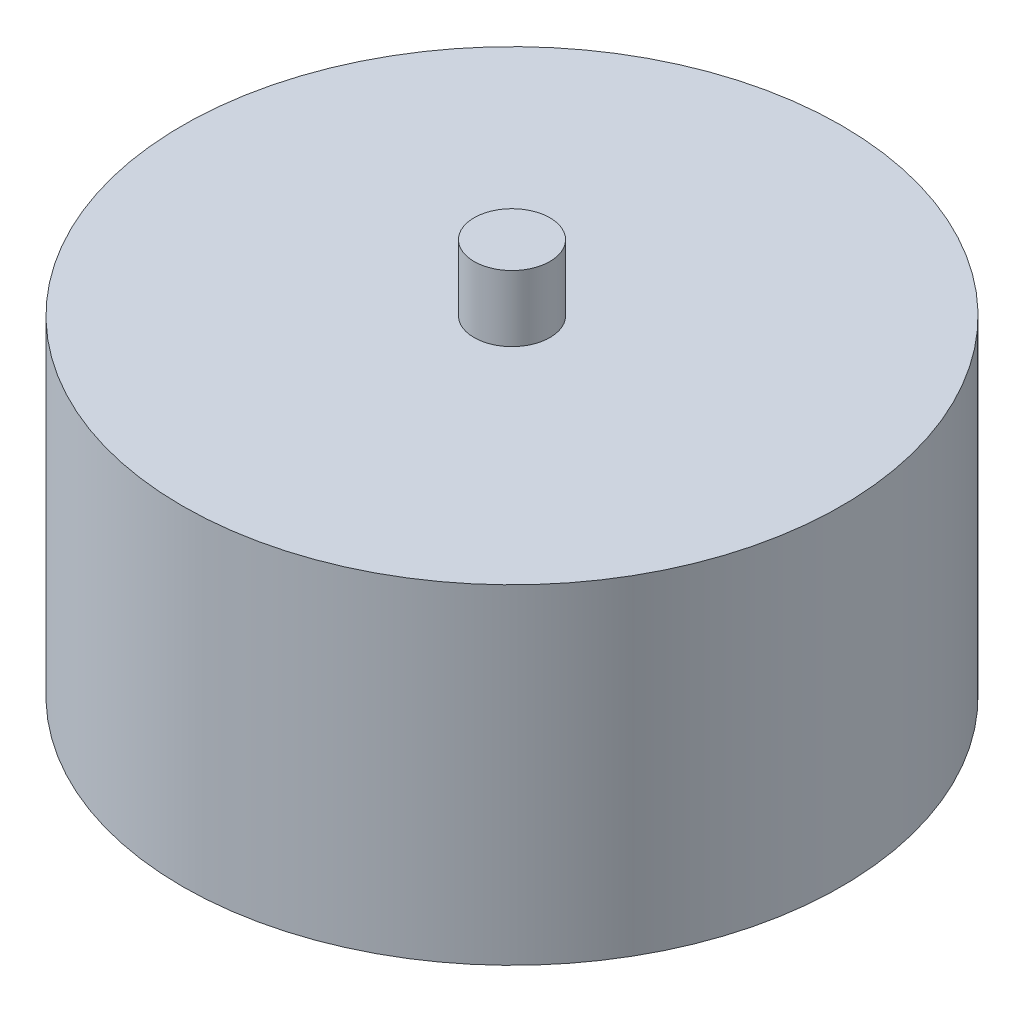
from build123d import *

# Parameters (mm, degrees)
SKETCH1_R           = 10
BOSS_EXTRUDE1_DEPTH = 10
SKETCH1_3_R         = 1.15
BOSS_EXTRUDE2_DEPTH = 2
CUT_EXTRUDE1_START  = -10
SKETCH1_4_R         = 1.5
CUT_EXTRUDE1_DEPTH  = 5


with BuildPart() as part:
    # Sketch1 → Boss-Extrude1 (new body)
    with BuildSketch(Plane(origin=(0, 0, 0), x_dir=(1, 0, 0), z_dir=(0, 1, 0))):
        Circle(SKETCH1_R)
    extrude(amount=-BOSS_EXTRUDE1_DEPTH)

    # Sketch1_3 → Boss-Extrude2 (add)
    with BuildSketch(Plane(origin=(0, 0, 0), x_dir=(1, 0, 0), z_dir=(0, 1, 0))):
        Circle(SKETCH1_3_R)
    extrude(amount=BOSS_EXTRUDE2_DEPTH)

    # Sketch1_4 → Cut-Extrude1 (cut)
    with BuildSketch(Plane(origin=(0, 0, 0), x_dir=(1, 0, 0), z_dir=(0, 1, 0)).offset(CUT_EXTRUDE1_START)):
        with Locations((6.495190528, -3.75)):
            Circle(SKETCH1_4_R)
        with Locations((-6.495190528, -3.75)):
            Circle(SKETCH1_4_R)
        with Locations((0, 7.5)):
            Circle(SKETCH1_4_R)
    extrude(amount=CUT_EXTRUDE1_DEPTH, mode=Mode.SUBTRACT)


solid = part.part
